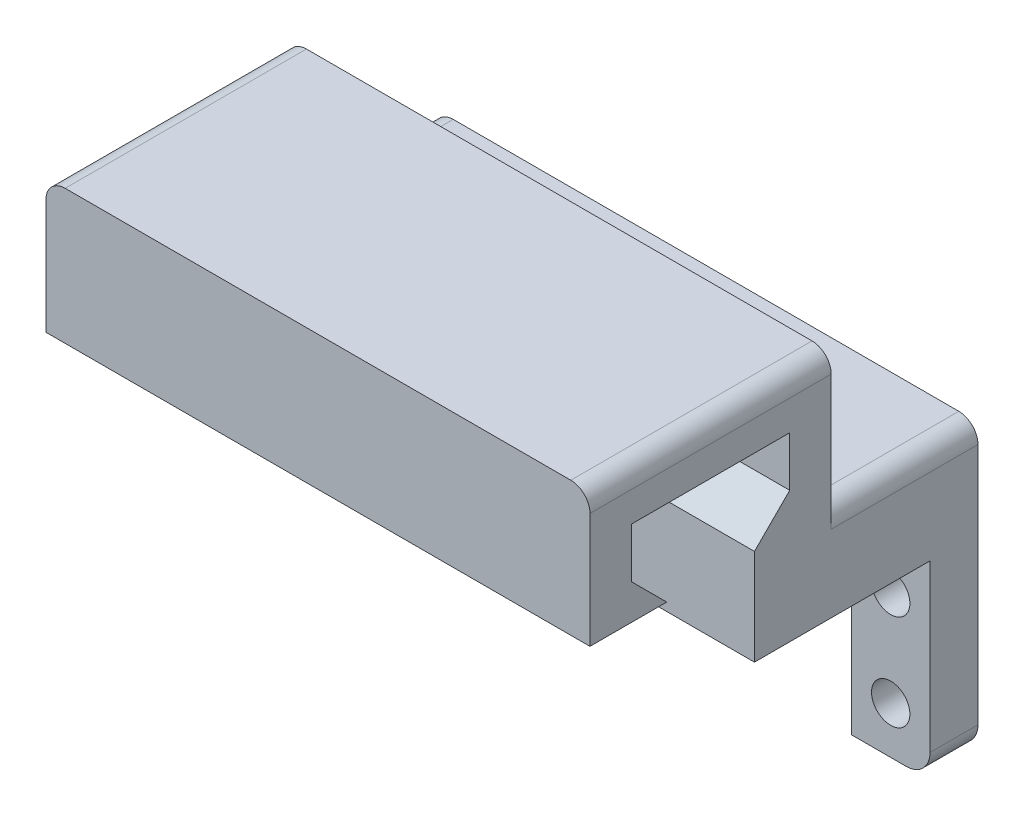
from build123d import *

# Parameters (mm, degrees)
SKETCH1_R               = 2
FORMA_B_SICA_DEPTH      = 5
FORMA_B_SICA_2_DEPTH    = 5
BOSS_EXTRUDE2_DEPTH     = 23.3
CARRIL_CREMALLERA_DEPTH = 56.7
ELIMINAR_FILETE_DEPTH   = 23.3
FILLET2_R               = 2


with BuildPart() as part:
    # Sketch1 → Forma básica (new body)
    with BuildSketch(Plane.XY):
        with BuildLine():
            ThreePointArc((-25.85, -9.9), (-27.617766953, -9.167766953), (-28.35, -7.4))
            Line((-28.35, -7.4), (-28.35, 9.9))
            Line((-28.35, 9.9), (-20.15, 9.9))
            Line((-20.15, 9.9), (-20.15, -9.9))
            Line((-20.15, -9.9), (-25.85, -9.9))
        make_face()
        with Locations((-24.25, -5)):
            Circle(SKETCH1_R, mode=Mode.SUBTRACT)
        with Locations((-24.25, 5)):
            Circle(SKETCH1_R, mode=Mode.SUBTRACT)
    extrude(amount=FORMA_B_SICA_DEPTH)



with BuildPart() as body_2:
    # Sketch1 → Forma b_sica 2 (new body)
    with BuildSketch(Plane.XY):
        with BuildLine():
            ThreePointArc((28.35, -7.4), (27.617766953, -9.167766953), (25.85, -9.9))
            Line((25.85, -9.9), (20.15, -9.9))
            Line((20.15, -9.9), (20.15, 9.9))
            Line((20.15, 9.9), (28.35, 9.9))
            Line((28.35, 9.9), (28.35, -7.4))
        make_face()
        with Locations((24.25, 5)):
            Circle(SKETCH1_R, mode=Mode.SUBTRACT)
        with Locations((24.25, -5)):
            Circle(SKETCH1_R, mode=Mode.SUBTRACT)
    extrude(amount=FORMA_B_SICA_2_DEPTH)


with BuildPart() as part_1:
    add(part.part)

    add(body_2.part)  # Boss-Extrude2 merges body 2
    # Sketch1_3 → Boss-Extrude2 (add)
    with BuildSketch(Plane.XY):
        with BuildLine():
            Line((-28.35, 9.9), (-20.15, 9.9))
            Line((-20.15, 9.9), (20.15, 9.9))
            Line((20.15, 9.9), (28.35, 9.9))
            Line((28.35, 9.9), (28.35, 17.4))
            ThreePointArc((28.35, 17.4), (27.617766953, 19.167766953), (25.85, 19.9))
            Line((25.85, 19.9), (-25.85, 19.9))
            ThreePointArc((-25.85, 19.9), (-27.617766953, 19.167766953), (-28.35, 17.4))
            Line((-28.35, 17.4), (-28.35, 9.9))
        make_face()
    extrude(amount=BOSS_EXTRUDE2_DEPTH)

    # Sketch2 → Carril cremallera (add)
    with BuildSketch(Plane(origin=(28.35, 0, 0), x_dir=(0, 0, -1), z_dir=(1, 0, 0))):
        Polygon((-23.3, 19.9), (-19.623044738, 23.576955262), (-19.623044738, 28.776955262), (-36.123044738, 28.776955262), (-36.123044738, 23.576955262), (-32.446089476, 19.9), (-40.446089476, 19.9), (-40.446089476, 33.9), (-15.3, 33.9), (-15.3, 19.9), align=None)
    extrude(amount=-CARRIL_CREMALLERA_DEPTH)

    # Sketch3 → Eliminar filete (add)
    with BuildSketch(Plane.XY.offset(23.3)):
        with BuildLine():
            Line((-28.35, 17.4), (-28.35, 19.9))
            Line((-28.35, 19.9), (-25.85, 19.9))
            ThreePointArc((-25.85, 19.9), (-27.617766953, 19.167766953), (-28.35, 17.4))
        make_face()
        with BuildLine():
            Line((28.35, 19.9), (25.85, 19.9))
            ThreePointArc((25.85, 19.9), (27.617766953, 19.167766953), (28.35, 17.4))
            Line((28.35, 17.4), (28.35, 19.9))
        make_face()
    extrude(amount=-ELIMINAR_FILETE_DEPTH)

    # Fillet2
    fillet2_edges = [part_1.edges().sort_by_distance(p)[0] for p in [
        (28.35, 33.9, 27.873044738),
        (-28.35, 33.9, 27.873044738),
        (-28.35, 19.9, 7.65),
        (28.35, 19.9, 7.65),
    ]]
    fillet(fillet2_edges, radius=FILLET2_R)


solid = part_1.part
